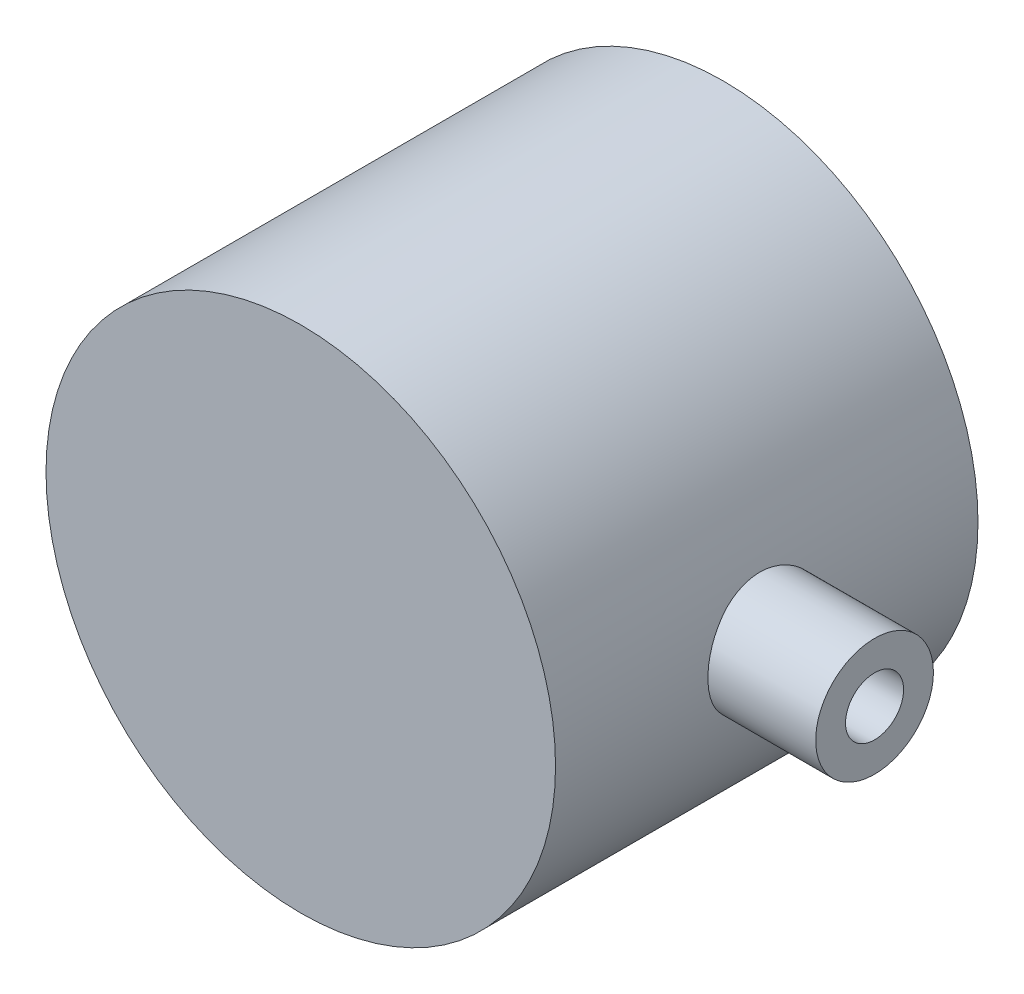
from build123d import *

# Parameters (mm, degrees)
SKETCH1_R                = 24.123
BOSS_EXTRUDE1_DEPTH      = 35
BOSS_EXTRUDE1_DEPTH_BACK = 5
SKETCH2_R                = 3.25
CUT_EXTRUDE2_DEPTH       = 19.25
CUT_EXTRUDE2_DEPTH_BACK  = 50
SKETCH4_R                = 3.25
CUT_EXTRUDE3_DEPTH       = 200
CUT_EXTRUDE8_START       = -24.123
SKETCH5_R                = 11.25
CUT_EXTRUDE8_DEPTH       = 5.033
CUT_EXTRUDE9_START       = -24.123
SKETCH6_R                = 11.25
CUT_EXTRUDE9_DEPTH       = 5.033
SKETCH7_R                = 17.25
CUT_EXTRUDE10_DEPTH      = 30
CUT_EXTRUDE11_START      = 19.25
SKETCH8_R                = 2.75
CUT_EXTRUDE11_DEPTH      = 24.873
BOSS_EXTRUDE2_START      = 23.125
SKETCH9_R                = 5.575
BOSS_EXTRUDE2_DEPTH      = 11.203
CUT_EXTRUDE12_DEPTH      = 50
CUT_EXTRUDE13_START      = -24.125
SKETCH10_R               = 12.25
CUT_EXTRUDE13_DEPTH      = 4
CUT_EXTRUDE14_START      = -24.125
SKETCH11_R               = 12.25
CUT_EXTRUDE14_DEPTH      = 4


with BuildPart() as part:
    # Sketch1 → Boss-Extrude1 (new body, two sides)
    with BuildSketch(Plane.XY) as boss_extrude1_sk:
        Circle(SKETCH1_R)
    extrude(amount=BOSS_EXTRUDE1_DEPTH)
    extrude(boss_extrude1_sk.sketch, amount=-BOSS_EXTRUDE1_DEPTH_BACK)

    # Sketch2 → Cut-Extrude2 (cut, two sides)
    with BuildSketch(Plane(origin=(0, 0, 0), x_dir=(0, 0, -1), z_dir=(1, 0, 0))) as cut_extrude2_sk:
        with Locations((-15, 0)):
            Circle(SKETCH2_R)
    extrude(amount=CUT_EXTRUDE2_DEPTH, mode=Mode.SUBTRACT)
    extrude(cut_extrude2_sk.sketch, amount=-CUT_EXTRUDE2_DEPTH_BACK, mode=Mode.SUBTRACT)

    # Sketch4 → Cut-Extrude3 (cut)
    with BuildSketch(Plane(origin=(0, 0, 0), x_dir=(1, 0, 0), z_dir=(0, 1, 0))):
        with Locations((0, -15)):
            Circle(SKETCH4_R)
    extrude(amount=-CUT_EXTRUDE3_DEPTH, mode=Mode.SUBTRACT)

    # Sketch5 → Cut-Extrude8 (cut)
    with BuildSketch(Plane(origin=(0, 0, 0), x_dir=(0, 0, -1), z_dir=(1, 0, 0)).offset(CUT_EXTRUDE8_START)):
        with Locations((-15, 0)):
            Circle(SKETCH5_R)
    extrude(amount=CUT_EXTRUDE8_DEPTH, mode=Mode.SUBTRACT)

    # Sketch6 → Cut-Extrude9 (cut)
    with BuildSketch(Plane(origin=(0, 0, 0), x_dir=(1, 0, 0), z_dir=(0, 1, 0)).offset(CUT_EXTRUDE9_START)):
        with Locations((0, -15)):
            Circle(SKETCH6_R)
    extrude(amount=CUT_EXTRUDE9_DEPTH, mode=Mode.SUBTRACT)

    # Sketch7 → Cut-Extrude10 (cut)
    with BuildSketch(Plane(origin=(0, 0, -5), x_dir=(-1, 0, 0), z_dir=(0, 0, -1))):
        Circle(SKETCH7_R)
    extrude(amount=-CUT_EXTRUDE10_DEPTH, mode=Mode.SUBTRACT)

    # Sketch8 → Cut-Extrude11 (cut)
    with BuildSketch(Plane(origin=(0, 0, 0), x_dir=(0, 0, -1), z_dir=(1, 0, 0)).offset(CUT_EXTRUDE11_START)):
        with Locations((-15, 0)):
            Circle(SKETCH8_R)
    extrude(amount=CUT_EXTRUDE11_DEPTH, mode=Mode.SUBTRACT)

    # Sketch10 → Cut-Extrude13 (cut)
    with BuildSketch(Plane(origin=(0, 0, 0), x_dir=(0, 0, -1), z_dir=(1, 0, 0)).offset(CUT_EXTRUDE13_START)):
        with Locations((-15, 0)):
            Circle(SKETCH10_R)
    extrude(amount=CUT_EXTRUDE13_DEPTH, mode=Mode.SUBTRACT)

    # Sketch11 → Cut-Extrude14 (cut)
    with BuildSketch(Plane(origin=(0, 0, 0), x_dir=(1, 0, 0), z_dir=(0, 1, 0)).offset(CUT_EXTRUDE14_START)):
        with Locations((0, -15)):
            Circle(SKETCH11_R)
    extrude(amount=CUT_EXTRUDE14_DEPTH, mode=Mode.SUBTRACT)


with BuildPart() as body_2:
    # Sketch9 → Boss-Extrude2 (new body)
    with BuildSketch(Plane(origin=(0, 0, 0), x_dir=(0, 0, -1), z_dir=(1, 0, 0)).offset(BOSS_EXTRUDE2_START)):
        with Locations((-15, 0)):
            Circle(SKETCH9_R)
    extrude(amount=BOSS_EXTRUDE2_DEPTH)

    # Sketch8 → Cut-Extrude12 (cut)
    with BuildSketch(Plane(origin=(0, 0, 0), x_dir=(0, 0, -1), z_dir=(1, 0, 0))):
        with Locations((-15, 0)):
            Circle(SKETCH8_R)
    extrude(amount=CUT_EXTRUDE12_DEPTH, mode=Mode.SUBTRACT)


solid = Compound([part.part, body_2.part])
